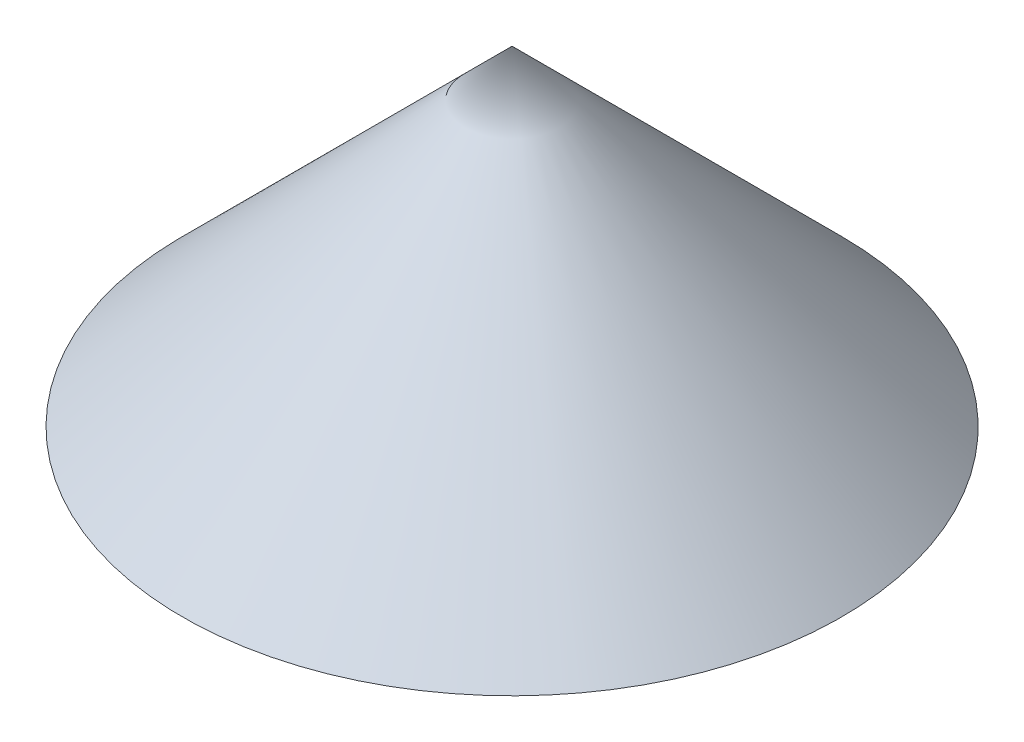
from build123d import *


with BuildPart() as part:
    # Sketch1 → Revolve1 (revolve)
    with BuildSketch(Plane.XY):
        Polygon((0, 0), (0, 10), (10, 0), align=None)
    revolve(axis=Axis((0, 0, 0), (0, 1, 0)))


solid = part.part
